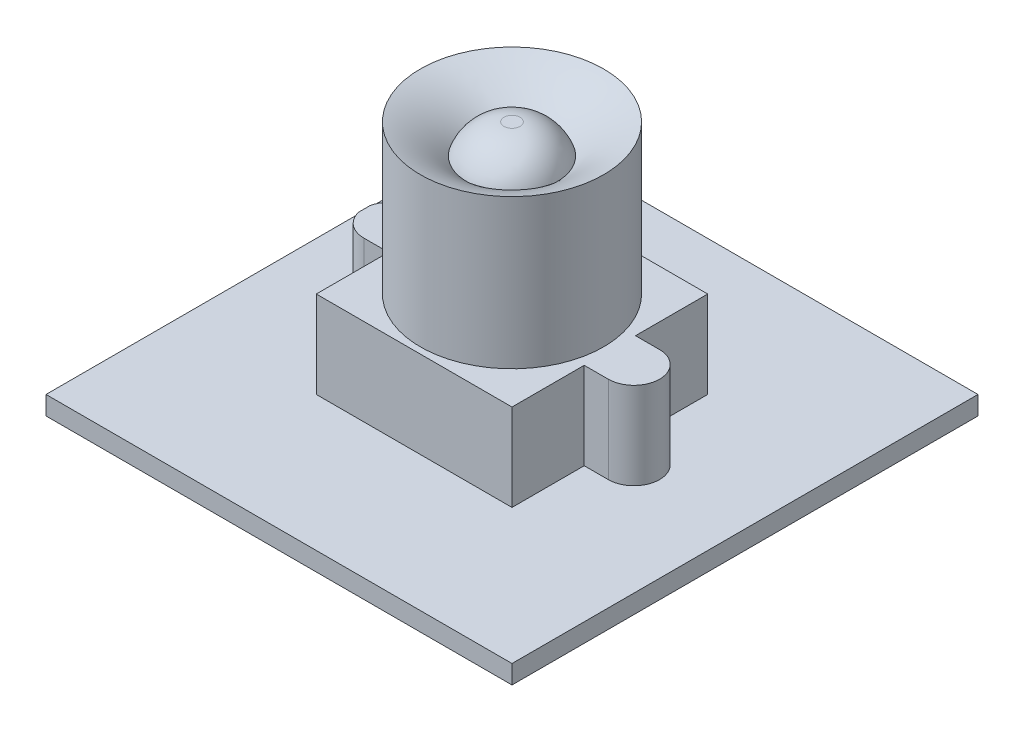
from build123d import *

# Parameters (mm, degrees)
SKETCH3_W           = 38.1
SKETCH3_H           = 38.1
BOSS_EXTRUDE2_DEPTH = 1.524
SKETCH4_W           = 16.002
SKETCH4_H           = 16.002
BOSS_EXTRUDE3_DEPTH = 7.112
SKETCH5_R           = 7.493
BOSS_EXTRUDE4_DEPTH = 12.192
BOSS_EXTRUDE6_DEPTH = 7.112


with BuildPart() as part:
    # Sketch3 → Boss-Extrude2 (new body)
    with BuildSketch(Plane(origin=(0, 0, 0), x_dir=(1, 0, 0), z_dir=(0, 1, 0))):
        Rectangle(SKETCH3_W, SKETCH3_H)
    extrude(amount=BOSS_EXTRUDE2_DEPTH)

    # Sketch4 → Boss-Extrude3 (add)
    with BuildSketch(Plane(origin=(0, 1.524, 0), x_dir=(1, 0, 0), z_dir=(0, 1, 0))):
        Rectangle(SKETCH4_W, SKETCH4_H)
    extrude(amount=BOSS_EXTRUDE3_DEPTH)

    # Sketch5 → Boss-Extrude4 (add)
    with BuildSketch(Plane(origin=(0, 8.636, 0), x_dir=(1, 0, 0), z_dir=(0, 1, 0))):
        with Locations(Location((0, 0, 0), (0, 0, 90))):
            Circle(SKETCH5_R)
    extrude(amount=BOSS_EXTRUDE4_DEPTH)

    # Sketch6 → Boss-Extrude6 (add)
    with BuildSketch(Plane(origin=(0, 8.636, 0), x_dir=(1, 0, 0), z_dir=(0, 1, 0))):
        with BuildLine():
            ThreePointArc((8.001, -0.71842049), (8.768319307, -1.717057132), (9.9695, -2.0955))
            ThreePointArc((9.9695, -2.0955), (11.45124226, -1.48174226), (12.065, 0))
            ThreePointArc((12.065, 0), (11.45124226, 1.48174226), (9.9695, 2.0955))
            ThreePointArc((9.9695, 2.0955), (8.768319307, 1.717057132), (8.001, 0.71842049))
            Line((8.001, 0.71842049), (8.001, -0.71842049))
        make_face()
        with BuildLine():
            ThreePointArc((8.001, 0.71842049), (7.874, 0), (8.001, -0.71842049))
            Line((8.001, -0.71842049), (8.001, 0.71842049))
        make_face()
        with BuildLine():
            Line((8.001, -2.0955), (9.9695, -2.0955))
            ThreePointArc((9.9695, -2.0955), (8.768319307, -1.717057132), (8.001, -0.71842049))
            Line((8.001, -0.71842049), (8.001, -2.0955))
        make_face()
        with BuildLine():
            Line((7.194020347, -2.0955), (8.001, -2.0955))
            Line((8.001, -2.0955), (8.001, -0.71842049))
            ThreePointArc((8.001, -0.71842049), (7.874, 0), (8.001, 0.71842049))
            Line((8.001, 0.71842049), (8.001, 2.0955))
            Line((8.001, 2.0955), (7.194020347, 2.0955))
            ThreePointArc((7.194020347, 2.0955), (7.417878519, 1.058360652), (7.493, 0))
            ThreePointArc((7.493, 0), (7.417878519, -1.058360652), (7.194020347, -2.0955))
        make_face()
        with BuildLine():
            ThreePointArc((8.001, 0.71842049), (8.768319307, 1.717057132), (9.9695, 2.0955))
            Line((9.9695, 2.0955), (8.001, 2.0955))
            Line((8.001, 2.0955), (8.001, 0.71842049))
        make_face()
        with BuildLine():
            Line((-7.194020347, -2.0955), (7.194020347, -2.0955))
            ThreePointArc((7.194020347, -2.0955), (7.417878519, -1.058360652), (7.493, 0))
            ThreePointArc((7.493, 0), (7.417878519, 1.058360652), (7.194020347, 2.0955))
            Line((7.194020347, 2.0955), (-7.194020347, 2.0955))
            ThreePointArc((-7.194020347, 2.0955), (-7.493, 0), (-7.194020347, -2.0955))
        make_face()
        with BuildLine():
            Line((-8.001, -2.0955), (-7.194020347, -2.0955))
            ThreePointArc((-7.194020347, -2.0955), (-7.493, 0), (-7.194020347, 2.0955))
            Line((-7.194020347, 2.0955), (-8.001, 2.0955))
            Line((-8.001, 2.0955), (-8.001, 0.55189456))
            ThreePointArc((-8.001, 0.55189456), (-7.945595412, 0.27841562), (-7.927017411, 0))
            ThreePointArc((-7.927017411, 0), (-7.945595412, -0.27841562), (-8.001, -0.55189456))
            Line((-8.001, -0.55189456), (-8.001, -2.0955))
        make_face()
        with BuildLine():
            ThreePointArc((-12.065, -0.468385659), (-11.328200782, -1.638997006), (-10.022517424, -2.0955))
            ThreePointArc((-10.022517424, -2.0955), (-8.750781359, -1.665475206), (-8.001, -0.55189456))
            Line((-8.001, -0.55189456), (-8.001, 0.55189456))
            ThreePointArc((-8.001, 0.55189456), (-8.75078136, 1.665475207), (-10.022517427, 2.0955))
            ThreePointArc((-10.022517427, 2.0955), (-11.328200783, 1.638997005), (-12.065, 0.468385659))
            Line((-12.065, 0.468385659), (-12.065, -0.468385659))
        make_face()
        with BuildLine():
            Line((-10.022517424, -2.0955), (-8.001, -2.0955))
            Line((-8.001, -2.0955), (-8.001, -0.55189456))
            ThreePointArc((-8.001, -0.55189456), (-8.750781359, -1.665475206), (-10.022517424, -2.0955))
        make_face()
        with BuildLine():
            Line((-8.001, 0.55189456), (-8.001, -0.55189456))
            ThreePointArc((-8.001, -0.55189456), (-7.945595412, -0.27841562), (-7.927017411, 0))
            ThreePointArc((-7.927017411, 0), (-7.945595412, 0.27841562), (-8.001, 0.55189456))
        make_face()
        with BuildLine():
            Line((-8.001, 0.55189456), (-8.001, 2.0955))
            Line((-8.001, 2.0955), (-10.022517427, 2.0955))
            ThreePointArc((-10.022517427, 2.0955), (-8.75078136, 1.665475207), (-8.001, 0.55189456))
        make_face()
    extrude(amount=-BOSS_EXTRUDE6_DEPTH)

    # Sketch8 → Cut-Revolve2 (revolve, cut)
    with BuildSketch(Plane.XY, mode=Mode.PRIVATE) as cut_revolve2_sk:
        with BuildLine():
            ThreePointArc((-3.683327211, 18.4271959), (-2.28773348, 20.259113148), (-0.056148749, 20.828))
            ThreePointArc((-0.056148749, 20.828), (-3.774574374, 21.391967579), (-7.493, 20.828))
            ThreePointArc((-7.493, 20.828), (-5.455602523, 19.837950118), (-3.683327211, 18.4271959))
        make_face()
    revolve(cut_revolve2_sk.sketch.rotate(Axis((0, 0, 0), (0, 1, 0)), 270), axis=Axis((0, 0, 0), (0, 1, 0)), mode=Mode.SUBTRACT)


solid = part.part
